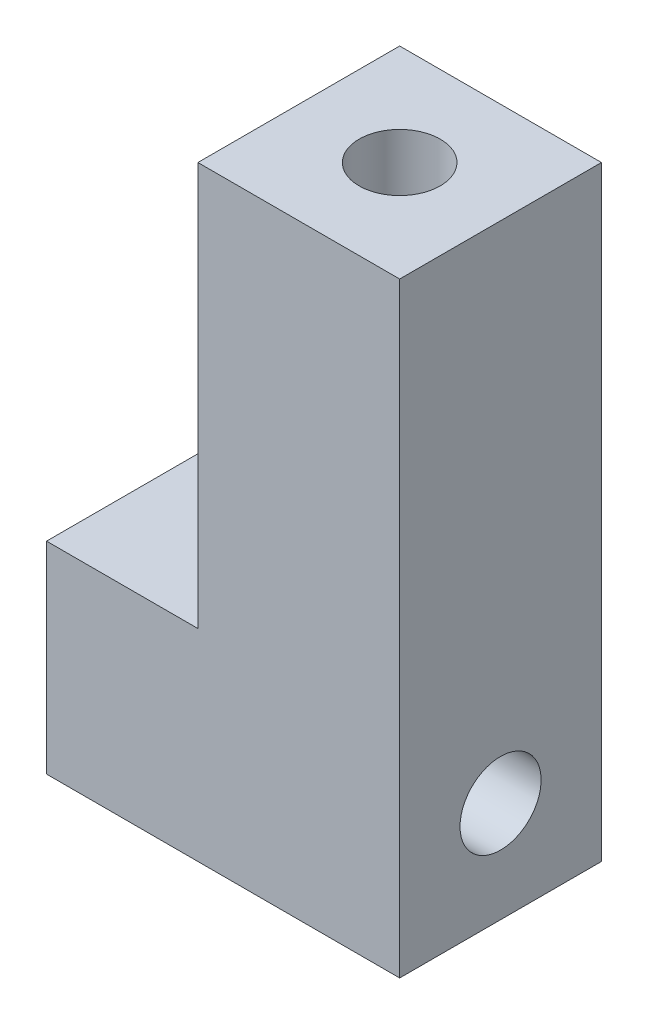
from build123d import *

# Parameters (mm, degrees)
BOSS_EXTRUDE1_DEPTH     = 12.7
F_1_4_20_TAPPED_HOLE1_D = 5.1054
F_1_4_20_TAPPED_HOLE2_D = 5.1054


with BuildPart() as part:
    # Sketch1 → Boss-Extrude1 (new body)
    with BuildSketch(Plane.XY):
        Polygon((0, 0), (0, 38.1), (-12.7, 38.1), (-12.7, 12.7), (-22.225, 12.7), (-22.225, 0), align=None)
    extrude(amount=BOSS_EXTRUDE1_DEPTH)

    # 1/4-20 Tapped Hole1 (through all)
    with Locations(Plane(origin=(0, 38.1, 0), x_dir=(1, 0, 0), z_dir=(0, 1, 0))):
        with Locations((-6.35, -6.35)):
            Hole(F_1_4_20_TAPPED_HOLE1_D / 2)

    # 1/4-20 Tapped Hole2 (through all)
    with Locations(Plane.ZY.offset(22.225)):
        with Locations((6.35, 6.35)):
            Hole(F_1_4_20_TAPPED_HOLE2_D / 2)


solid = part.part
